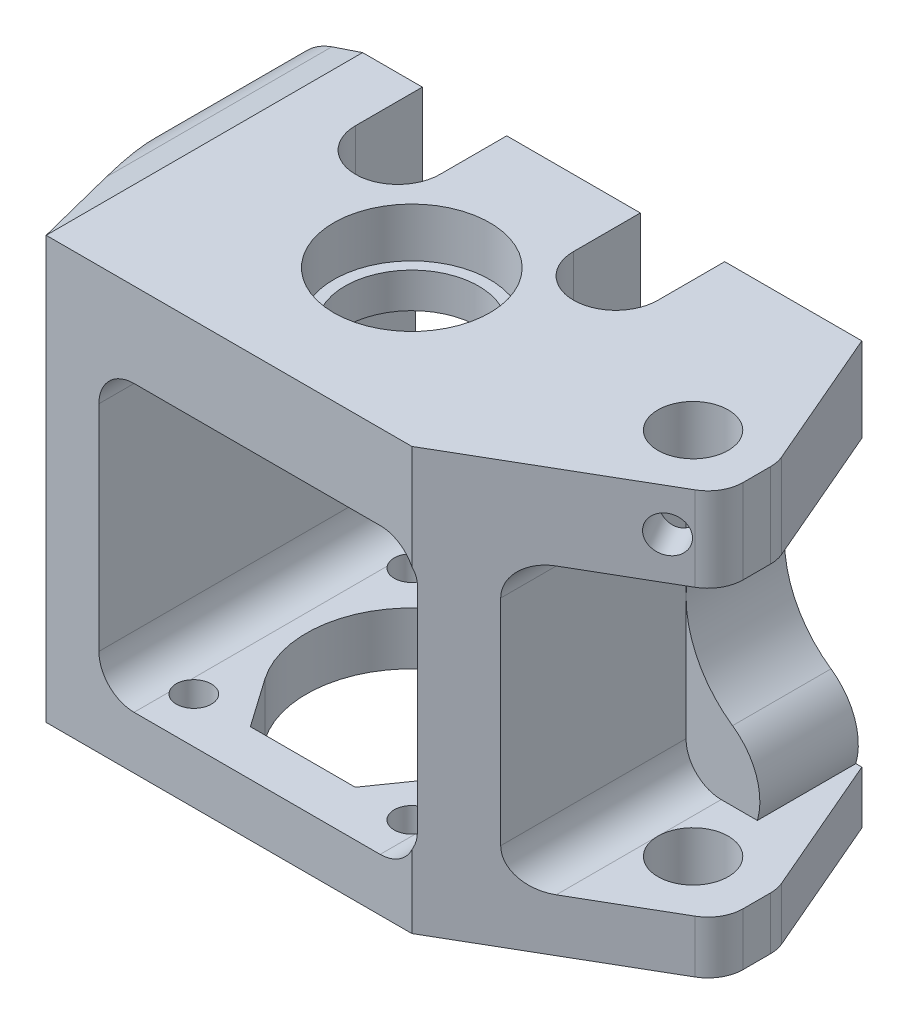
from build123d import *

# Parameters (mm, degrees)
SKETCH1_R           = 9.5
SKETCH1_R_2         = 5
BOSS_EXTRUDE1_DEPTH = 60
SKETCH2_R           = 11.1
CUT_EXTRUDE1_DEPTH  = 7
CUT_EXTRUDE2_DEPTH  = 31
SKETCH4_R           = 2.5
CUT_EXTRUDE3_DEPTH  = 16
SKETCH7_W           = 10.5
SKETCH7_H           = 60
BOSS_EXTRUDE2_DEPTH = 14
BOSS_EXTRUDE3_DEPTH = 60
SKETCH5_R           = 4
CUT_EXTRUDE4_DEPTH  = 13
CUT_EXTRUDE5_DEPTH  = 46.0000001
FILLET1_R           = 5
SKETCH9_R           = 2.6
CUT_EXTRUDE6_DEPTH  = 10
CUT_EXTRUDE7_DEPTH  = 20


with BuildPart() as part:
    # Sketch1 → Boss-Extrude1 (new body)
    with BuildSketch(Plane(origin=(0, 0, 0), x_dir=(1, 0, 0), z_dir=(0, 1, 0))):
        Polygon((-30, 23), (41, 23), (50, 2.057780588), (50, -5.760336739), (22, -22), (-30, -22), align=None)
        with Locations(Location((0, 0, 0), (0, 0, 270))):  # turned: the seam where the file's is
            Circle(SKETCH1_R, mode=Mode.SUBTRACT)
        with Locations(Location((40, 0, 0), (0, 0, 270))):  # turned: the seam where the file's is
            Circle(SKETCH1_R_2, mode=Mode.SUBTRACT)
    extrude(amount=BOSS_EXTRUDE1_DEPTH)

    # Sketch2 → Cut-Extrude1 (cut)
    with BuildSketch(Plane(origin=(0, 60, 0), x_dir=(1, 0, 0), z_dir=(0, 1, 0))):
        with Locations(Location((0, 0, 0), (0, 0, 270))):  # turned: the seam where the file's is
            Circle(SKETCH2_R)
    extrude(amount=-CUT_EXTRUDE1_DEPTH, mode=Mode.SUBTRACT)

    # Sketch3 → Cut-Extrude2 (cut)
    with BuildSketch(Plane.XY.offset(22)):
        with BuildLine():
            Line((-17.5, 48), (17.5, 48))
            ThreePointArc((17.5, 48), (21.035533906, 46.535533906), (22.5, 43))
            Line((22.5, 43), (22.5, 12.5))
            ThreePointArc((22.5, 12.5), (21.035533906, 8.964466094), (17.5, 7.5))
            Line((17.5, 7.5), (-17.5, 7.5))
            ThreePointArc((-17.5, 7.5), (-21.035533906, 8.964466094), (-22.5, 12.5))
            Line((-22.5, 12.5), (-22.5, 43))
            ThreePointArc((-22.5, 43), (-21.035533906, 46.535533906), (-17.5, 48))
        make_face()
        with BuildLine():
            Line((35, 48), (66.370981508, 48))
            Line((66.370981508, 48), (66.370981508, 7.5))
            Line((66.370981508, 7.5), (35, 7.5))
            ThreePointArc((35, 7.5), (31.464466094, 8.964466094), (30, 12.5))
            Line((30, 12.5), (30, 43))
            ThreePointArc((30, 43), (31.464466094, 46.535533906), (35, 48))
        make_face()
    extrude(amount=-CUT_EXTRUDE2_DEPTH, mode=Mode.SUBTRACT)

    # Sketch4 → Cut-Extrude3 (cut)
    with BuildSketch(Plane.XZ):
        with Locations(Location((15.5, 15.5, 0), (0, 0, 270))):  # turned: the seam where the file's is
            Circle(SKETCH4_R)
        with Locations(Location((-15.5, 15.5, 0), (0, 0, 270))):  # turned: the seam where the file's is
            Circle(SKETCH4_R)
        with Locations(Location((-15.5, -15.5, 0), (0, 0, 270))):  # turned: the seam where the file's is
            Circle(SKETCH4_R)
        with Locations(Location((15.5, -15.5, 0), (0, 0, 270))):  # turned: the seam where the file's is
            Circle(SKETCH4_R)
        with BuildLine():
            Line((-12.287280664, 8.603646545), (-7.458401989, 15.5))
            Line((-7.458401989, 15.5), (7.458401989, 15.5))
            Line((7.458401989, 15.5), (12.287280664, 8.603646545))
            ThreePointArc((12.287280664, 8.603646545), (0, -15), (-12.287280664, 8.603646545))
        make_face()
    extrude(amount=-CUT_EXTRUDE3_DEPTH, mode=Mode.SUBTRACT)

    # Sketch7 → Boss-Extrude2 (add)
    with BuildSketch(Plane(origin=(0, 0, -23), x_dir=(-1, 0, 0), z_dir=(0, 0, -1))):
        with Locations((35.25, 30)):
            Rectangle(SKETCH7_W, SKETCH7_H)
    extrude(amount=-BOSS_EXTRUDE2_DEPTH)

    # Sketch8 → Boss-Extrude3 (add)
    with BuildSketch(Plane.XZ):
        Polygon((-40.5, -9), (-30, 22), (-30, -9), align=None)
    extrude(amount=-BOSS_EXTRUDE3_DEPTH)

    # Sketch5 → Cut-Extrude4 (cut)
    with BuildSketch(Plane(origin=(0, 0, -23), x_dir=(-1, 0, 0), z_dir=(0, 0, -1))):
        with Locations((31.5, 50)):
            Circle(SKETCH5_R)
        with Locations((31.5, 10)):
            Circle(SKETCH5_R)
        with Locations((-31.5, 10)):
            Circle(SKETCH5_R)
        with Locations((-31.5, 50)):
            Circle(SKETCH5_R)
    extrude(amount=-CUT_EXTRUDE4_DEPTH, mode=Mode.SUBTRACT)

    # Sketch6 → Cut-Extrude5 (cut, through all)
    with BuildSketch(Plane(origin=(0, 0, -23), x_dir=(-1, 0, 0), z_dir=(0, 0, -1))):
        with BuildLine():
            Line((17.5, 48), (-17.5, 48))
            ThreePointArc((-17.5, 48), (-21.035533906, 46.535533906), (-22.5, 43))
            Line((-22.5, 43), (-22.5, 12.5))
            ThreePointArc((-22.5, 12.5), (-21.035533906, 8.964466094), (-17.5, 7.5))
            Line((-17.5, 7.5), (17.5, 7.5))
            ThreePointArc((17.5, 7.5), (21.035533906, 8.964466094), (22.5, 12.5))
            Line((22.5, 12.5), (22.5, 43))
            ThreePointArc((22.5, 43), (21.035533906, 46.535533906), (17.5, 48))
        make_face()
        with BuildLine():
            Line((34.369237169, 58.530385575), (30, 60))
            Line((30, 60), (30, 65.619685256))
            Line((30, 65.619685256), (48.74877155, 65.619685256))
            Line((48.74877155, 65.619685256), (48.74877155, -4.23456535))
            Line((48.74877155, -4.23456535), (30, -4.23456535))
            Line((30, -4.23456535), (30, 0))
            Line((30, 0), (34.369237169, 1.469614425))
            ThreePointArc((34.369237169, 1.469614425), (40.412298518, 8.746630491), (36.610730034, 17.408133268))
            ThreePointArc((36.610730034, 17.408133268), (30, 30), (36.610730034, 42.591866732))
            ThreePointArc((36.610730034, 42.591866732), (40.412298518, 51.253369509), (34.369237169, 58.530385575))
        make_face()
        with BuildLine():
            Line((-50, 48), (-40.274964387, 48))
            ThreePointArc((-40.274964387, 48), (-38.950845842, 44.951743247), (-36.610730034, 42.591866732))
            ThreePointArc((-36.610730034, 42.591866732), (-30, 30), (-36.610730034, 17.408133268))
            ThreePointArc((-36.610730034, 17.408133268), (-39.976636272, 13.024340839), (-40.145808233, 7.5))
            Line((-40.145808233, 7.5), (-50, 7.5))
            Line((-50, 7.5), (-50, 48))
        make_face()
    extrude(amount=-CUT_EXTRUDE5_DEPTH, mode=Mode.SUBTRACT)

    # Fillet1
    fillet1_edges = [part.edges().sort_by_distance(p)[0] for p in [
        (50, 54, -2.057780588),
        (50, 54, 5.760336739),
        (50, 3.75, -2.057780588),
        (50, 3.75, 5.760336739),
    ]]
    fillet(fillet1_edges, radius=FILLET1_R)

    # Sketch9 → Cut-Extrude6 (cut)
    with BuildSketch(Plane(origin=(15.085632266, 0, 26.010250131), x_dir=(0.865035704, 0, -0.501710305), z_dir=(0.501710305, 0, 0.865035704))):
        with Locations((34.60142817, 54)):
            Circle(SKETCH9_R)
    extrude(amount=-CUT_EXTRUDE6_DEPTH, mode=Mode.SUBTRACT)

    # Sketch10 → Cut-Extrude7 (cut)
    with BuildSketch(Plane(origin=(0, 60, 0), x_dir=(1, 0, 0), z_dir=(0, 1, 0))):
        with BuildLine():
            Line((21.5, 23), (9.5, 23))
            Line((9.5, 23), (9.5, 13.5))
            ThreePointArc((9.5, 13.5), (15.5, 7.5), (21.5, 13.5))
            Line((21.5, 13.5), (21.5, 23))
        make_face()
        with BuildLine():
            Line((-21.5, 13.5), (-21.5, 23))
            Line((-21.5, 23), (-9.5, 23))
            Line((-9.5, 23), (-9.5, 13.5))
            ThreePointArc((-9.5, 13.5), (-15.5, 7.5), (-21.5, 13.5))
        make_face()
    extrude(amount=-CUT_EXTRUDE7_DEPTH, mode=Mode.SUBTRACT)


solid = part.part
